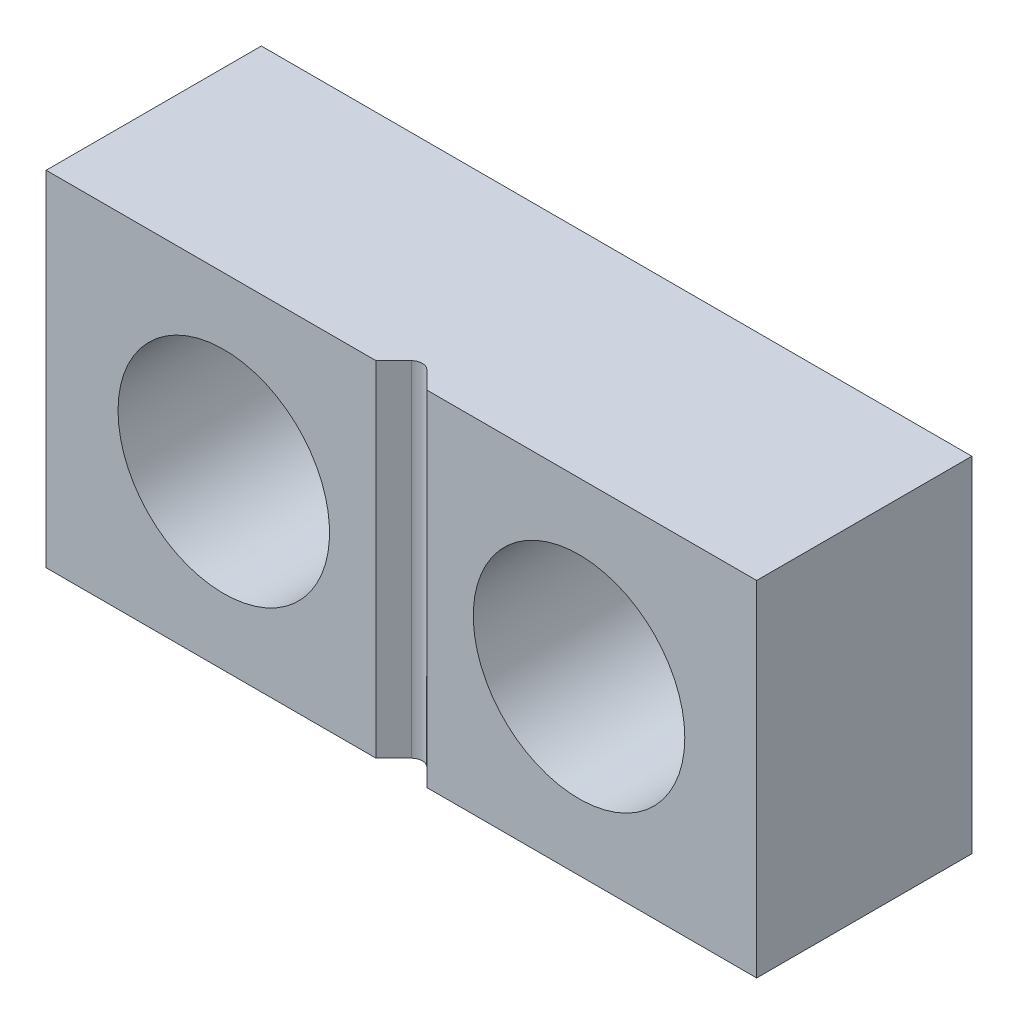
from build123d import *

# Parameters (mm, degrees)
SKETCH2_W               = 16.51
SKETCH2_H               = 8
SKETCH2_R               = 2.45745
BASE_EXTRUDE_DEPTH      = 5
CUT_EXTRUDE2_DEPTH      = 5
CUT_EXTRUDE2_DEPTH_BACK = 5


with BuildPart() as part:
    # Sketch2 → Base-Extrude (new body)
    with BuildSketch(Plane.XY):
        Rectangle(SKETCH2_W, SKETCH2_H)
        with Locations((4.1275, 0)):
            Circle(SKETCH2_R, mode=Mode.SUBTRACT)
        with Locations(Location((-4.1275, 0, 0), (0, 0, 180))):  # turned: the seam where the file's is
            Circle(SKETCH2_R, mode=Mode.SUBTRACT)
    extrude(amount=-BASE_EXTRUDE_DEPTH)

    # Sketch3 → Cut-Extrude2 (cut, two sides)
    with BuildSketch(Plane(origin=(0, 0, 0), x_dir=(-1, 0, 0), z_dir=(0, 1, 0))) as cut_extrude2_sk:
        with BuildLine():
            Line((0.590493938, 0), (0.179605122, -0.410888816))
            ThreePointArc((0.179605122, -0.410888816), (0, -0.485283694), (-0.179605122, -0.410888816))
            Line((-0.179605122, -0.410888816), (-0.590493938, 0))
            Line((-0.590493938, 0), (0.590493938, 0))
        make_face()
    extrude(amount=CUT_EXTRUDE2_DEPTH, mode=Mode.SUBTRACT)
    extrude(cut_extrude2_sk.sketch, amount=-CUT_EXTRUDE2_DEPTH_BACK, mode=Mode.SUBTRACT)


solid = part.part
